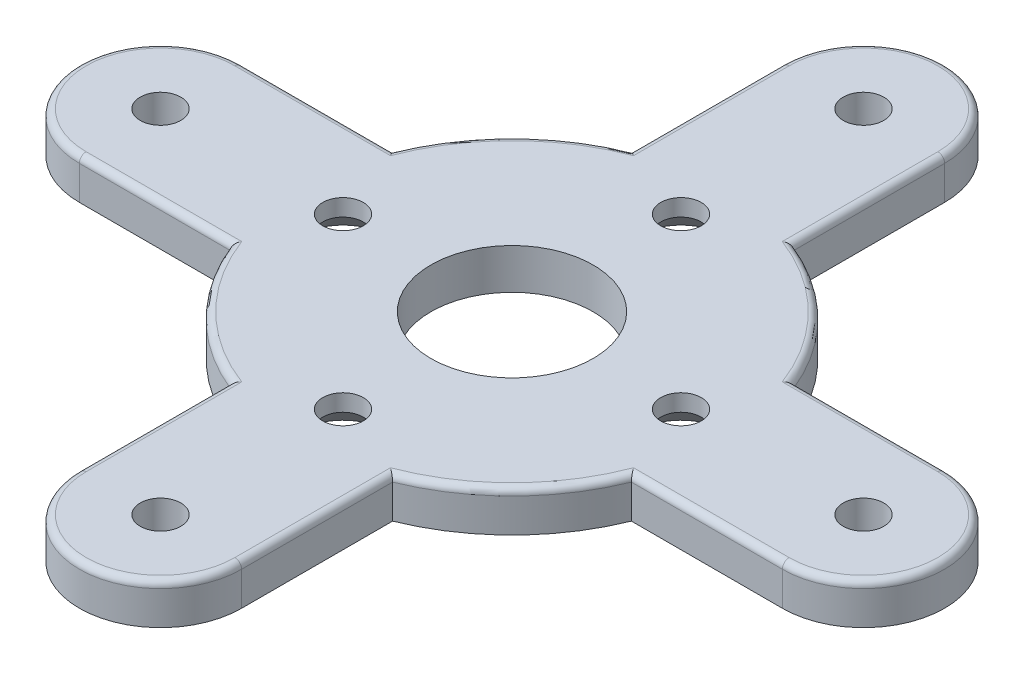
from build123d import *

# Parameters (mm, degrees)
SKETCH1_R           = 6
SKETCH1_R_2         = 1.5
BOSS_EXTRUDE1_DEPTH = 3
FILLET1_R           = 0.5
SKETCH2_R           = 1.5
CUT_EXTRUDE1_DEPTH  = 4
CHAMFER1_SIZE       = 1.75


with BuildPart() as part:
    # Sketch1 → Boss-Extrude1 (new body)
    with BuildSketch(Plane(origin=(0, 0, 0), x_dir=(1, 0, 0), z_dir=(0, 1, 0))):
        with BuildLine():
            Line((26, 6), (14.832396974, 6))
            ThreePointArc((14.832396974, 6), (11.313708499, 11.313708499), (6, 14.832396974))
            Line((6, 14.832396974), (6, 26))
            ThreePointArc((6, 26), (0, 32), (-6, 26))
            Line((-6, 26), (-6, 14.832396974))
            ThreePointArc((-6, 14.832396974), (-11.313708499, 11.313708499), (-14.832396974, 6))
            Line((-14.832396974, 6), (-26, 6))
            ThreePointArc((-26, 6), (-32, 0), (-26, -6))
            Line((-26, -6), (-14.832396974, -6))
            ThreePointArc((-14.832396974, -6), (-11.313708499, -11.313708499), (-6, -14.832396974))
            Line((-6, -14.832396974), (-6, -26))
            ThreePointArc((-6, -26), (0, -32), (6, -26))
            Line((6, -26), (6, -14.832396974))
            ThreePointArc((6, -14.832396974), (11.313708499, -11.313708499), (14.832396974, -6))
            Line((14.832396974, -6), (26, -6))
            ThreePointArc((26, -6), (32, 0), (26, 6))
        make_face()
        Circle(SKETCH1_R, mode=Mode.SUBTRACT)
        with Locations((0, 26)):
            Circle(SKETCH1_R_2, mode=Mode.SUBTRACT)
        with Locations((26, 0)):
            Circle(SKETCH1_R_2, mode=Mode.SUBTRACT)
        with Locations((0, -26)):
            Circle(SKETCH1_R_2, mode=Mode.SUBTRACT)
        with Locations((-26, 0)):
            Circle(SKETCH1_R_2, mode=Mode.SUBTRACT)
    extrude(amount=BOSS_EXTRUDE1_DEPTH)

    # Fillet1
    fillet1_edges = [part.edges().sort_by_distance(p)[0] for p in [
        (-11.313708499, 3, -11.313708499),
        (-20.416198487, 3, -6),
        (-32, 3, 0),
        (-20.416198487, 3, 6),
        (-11.313708499, 3, 11.313708499),
        (-6, 3, 20.416198487),
        (0, 3, 32),
        (6, 3, 20.416198487),
        (11.313708499, 3, 11.313708499),
        (20.416198487, 3, 6),
        (0, 3, -32),
        (32, 3, 0),
        (20.416198487, 3, -6),
        (11.313708499, 3, -11.313708499),
        (6, 3, -20.416198487),
        (-6, 3, -20.416198487),
    ]]
    fillet(fillet1_edges, radius=FILLET1_R)

    # Sketch2 → Cut-Extrude1 (cut, through all)
    with BuildSketch(Plane(origin=(0, 3, 0), x_dir=(1, 0, 0), z_dir=(0, 1, 0))):
        with Locations((0, 12.5)):
            Circle(SKETCH2_R)
        with Locations((12.5, 0)):
            Circle(SKETCH2_R)
        with Locations((0, -12.5)):
            Circle(SKETCH2_R)
        with Locations((-12.5, 0)):
            Circle(SKETCH2_R)
    extrude(amount=-CUT_EXTRUDE1_DEPTH, mode=Mode.SUBTRACT)

    # Chamfer1
    chamfer1_edges = [part.edges().sort_by_distance(p)[0] for p in [
        (-1.5, 0, -12.5),
        (11, 0, 0),
        (-1.5, 0, 12.5),
        (-14, 0, 0),
    ]]
    chamfer(chamfer1_edges, length=CHAMFER1_SIZE)


solid = part.part
